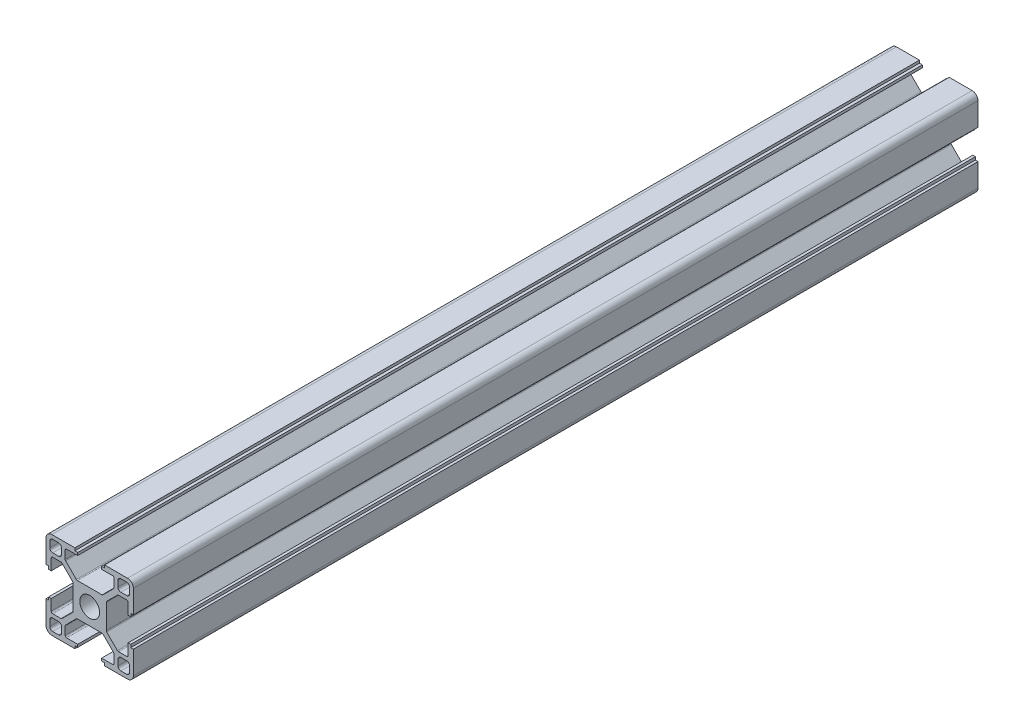
from build123d import *

# Parameters (mm, degrees)
SKETCH_1_W                       = 4
SKETCH_1_H                       = 4
EXTRUDE_1_DEPTH                  = 290
FILLET_1_R                       = 1
FILLET_2_R                       = 2
FILLET_3_R                       = 0.5
PATTERN_CIRCULAR_1_COUNT         = 4
FILLET_1_OF_PATTERN_CIRCULAR_1_R = 1
FILLET_2_OF_PATTERN_CIRCULAR_1_R = 2
FILLET_3_OF_PATTERN_CIRCULAR_1_R = 0.5
SKETCH_2_R                       = 3.4
CUT_EXTRUDE_1_DEPTH              = 291
SKETCH_3_R                       = 3.05
CUT_EXTRUDE_2_DEPTH              = 10


with BuildPart() as part:
    # 草图1 → 凸台-拉伸1 (new body)
    with BuildSketch(Plane.XY):
        Polygon((5.7, 0), (5.7, 4.427207794), (9.672792206, 8.4), (13.2, 8.4), (13.2, 4.1), (14.1, 4.1), (14.1, 5.1), (15, 5.1), (15, 15), (5.1, 15), (5.1, 14.1), (4.1, 14.1), (4.1, 13.2), (8.4, 13.2), (8.4, 9.672792206), (4.427207794, 5.7), (0, 5.7), (0, 0), align=None)
        with Locations((11.7, 11.7)):
            Rectangle(SKETCH_1_W, SKETCH_1_H, mode=Mode.SUBTRACT)
    extrude_1 = extrude(amount=EXTRUDE_1_DEPTH)

    # 圆角1
    fillet_1_edges = [part.edges().sort_by_distance(p)[0] for p in [
        (13.7, 9.7, 145),
        (13.7, 13.7, 145),
        (9.7, 13.7, 145),
        (9.7, 9.7, 145),
    ]]
    fillet(fillet_1_edges, radius=FILLET_1_R)

    # 圆角2
    fillet_2_edges = [part.edges().sort_by_distance(p)[0] for p in [
        (15, 15, 145),
    ]]
    fillet(fillet_2_edges, radius=FILLET_2_R)

    # 圆角3
    fillet_3_edges = [part.edges().sort_by_distance(p)[0] for p in [
        (4.427207794, 5.7, 145),
        (8.4, 9.672792206, 145),
        (8.4, 13.2, 145),
        (13.2, 8.4, 145),
        (9.672792206, 8.4, 145),
        (5.7, 4.427207794, 145),
    ]]
    fillet(fillet_3_edges, radius=FILLET_3_R)

    # 阵列(圆周)1: 凸台-拉伸1 ×4 about axis
    pattern_circular_1_axis = Axis((0, 0, 0), (0, 0, 1))
    for i in range(1, PATTERN_CIRCULAR_1_COUNT):
        add(extrude_1.rotate(pattern_circular_1_axis, i * 360 / PATTERN_CIRCULAR_1_COUNT))

    # 圆角1 of 阵列(圆周)1
    fillet_1_of_pattern_circular_1_edges = [part.edges().sort_by_distance(p)[0] for p in [
        (-9.7, 13.7, 145),
        (-13.7, 13.7, 145),
        (-13.7, 9.7, 145),
        (-9.7, 9.7, 145),
        (-13.7, -9.7, 145),
        (-13.7, -13.7, 145),
        (-9.7, -13.7, 145),
        (-9.7, -9.7, 145),
        (9.7, -13.7, 145),
        (13.7, -13.7, 145),
        (13.7, -9.7, 145),
        (9.7, -9.7, 145),
    ]]
    fillet(fillet_1_of_pattern_circular_1_edges, radius=FILLET_1_OF_PATTERN_CIRCULAR_1_R)

    # 圆角2 of 阵列(圆周)1
    fillet_2_of_pattern_circular_1_edges = [part.edges().sort_by_distance(p)[0] for p in [
        (-15, 15, 145),
        (-15, -15, 145),
        (15, -15, 145),
    ]]
    fillet(fillet_2_of_pattern_circular_1_edges, radius=FILLET_2_OF_PATTERN_CIRCULAR_1_R)

    # 圆角3 of 阵列(圆周)1
    fillet_3_of_pattern_circular_1_edges = [part.edges().sort_by_distance(p)[0] for p in [
        (-5.7, 4.427207794, 145),
        (-9.672792206, 8.4, 145),
        (-13.2, 8.4, 145),
        (-8.4, 13.2, 145),
        (-8.4, 9.672792206, 145),
        (-4.427207794, 5.7, 145),
        (-4.427207794, -5.7, 145),
        (-8.4, -9.672792206, 145),
        (-8.4, -13.2, 145),
        (-13.2, -8.4, 145),
        (-9.672792206, -8.4, 145),
        (-5.7, -4.427207794, 145),
        (5.7, -4.427207794, 145),
        (9.672792206, -8.4, 145),
        (13.2, -8.4, 145),
        (8.4, -13.2, 145),
        (8.4, -9.672792206, 145),
        (4.427207794, -5.7, 145),
    ]]
    fillet(fillet_3_of_pattern_circular_1_edges, radius=FILLET_3_OF_PATTERN_CIRCULAR_1_R)

    # 草图2 → 切除-拉伸1 (cut, through all)
    with BuildSketch(Plane.XY.offset(290)):
        Circle(SKETCH_2_R)
    extrude(amount=-CUT_EXTRUDE_1_DEPTH, mode=Mode.SUBTRACT)

    # 草图3 → 切除-拉伸2 (cut, symmetric)
    with BuildSketch(Plane(origin=(0, 0, 0), x_dir=(0, 0, -1), z_dir=(1, 0, 0))):
        with Locations((-145, 0)):
            Circle(SKETCH_3_R)
    extrude(amount=CUT_EXTRUDE_2_DEPTH, both=True, mode=Mode.SUBTRACT)


solid = part.part
